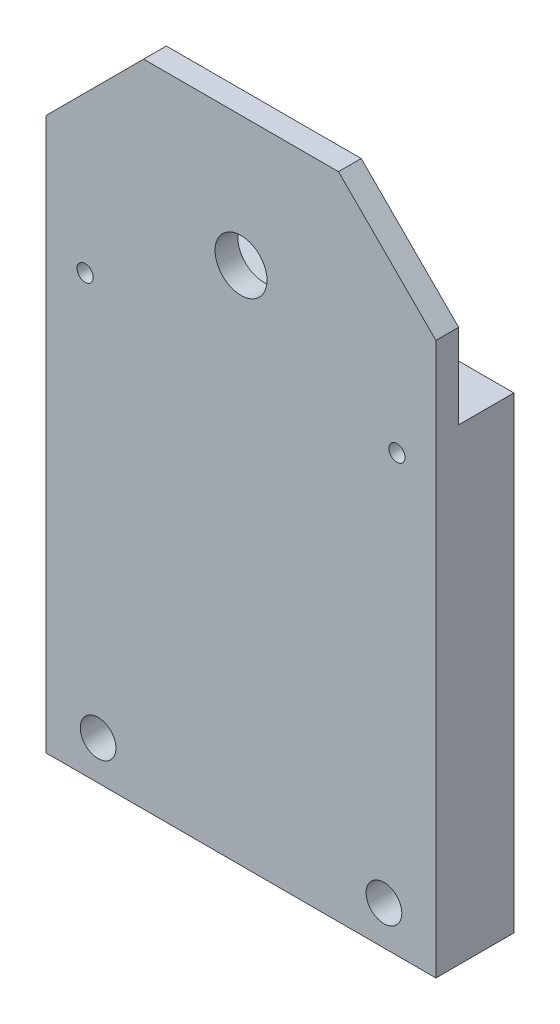
from build123d import *

# Parameters (mm, degrees)
ESQUISSE2_W                                        = 60
ESQUISSE2_H                                        = 100
BOSS_EXTRU_1_DEPTH                                 = 12
ESQUISSE3_R                                        = 4
ENL_V_MAT_EXTRU_1_DEPTH                            = 3.5
ESQUISSE5_W                                        = 8.5
ESQUISSE5_H                                        = 28
ENL_V_MAT_EXTRU_2_DEPTH                            = 61
TROU_TARAUD_M31_D                                  = 2.5
TROU_TARAUD_M32_D                                  = 2.5
CHAMBRAGE_POUR_VIS_T_TE_HEXAGONALE_M51_D           = 5.5
CHAMBRAGE_POUR_VIS_T_TE_HEXAGONALE_M51_CBORE_D     = 10
CHAMBRAGE_POUR_VIS_T_TE_HEXAGONALE_M51_CBORE_DEPTH = 5
CHAMBRAGE_POUR_VIS_T_TE_HEXAGONALE_M52_D           = 5.5
CHAMBRAGE_POUR_VIS_T_TE_HEXAGONALE_M52_CBORE_D     = 10
CHAMBRAGE_POUR_VIS_T_TE_HEXAGONALE_M52_CBORE_DEPTH = 5
CHANFREIN1_SIZE                                    = 15


with BuildPart() as part:
    # Esquisse2 → Boss.-Extru.1 (new body)
    with BuildSketch(Plane.XY):
        with Locations((30, 50)):
            Rectangle(ESQUISSE2_W, ESQUISSE2_H)
    extrude(amount=BOSS_EXTRU_1_DEPTH)

    # Esquisse3 → Enlèv. mat.-Extru.1 (cut)
    with BuildSketch(Plane.XY.offset(12)):
        with Locations((30, 80)):
            Circle(ESQUISSE3_R)
    extrude(amount=-ENL_V_MAT_EXTRU_1_DEPTH, mode=Mode.SUBTRACT)

    # Esquisse5 → Enlèv. mat.-Extru.2 (cut, through all)
    with BuildSketch(Plane.ZY):
        with Locations((4.25, 86)):
            Rectangle(ESQUISSE5_W, ESQUISSE5_H)
    extrude(amount=-ENL_V_MAT_EXTRU_2_DEPTH, mode=Mode.SUBTRACT)

    # Trou taraudé M31 (through all)
    with Locations(Plane.XY.offset(12)):
        with Locations((54, 67), (30, 80)):
            Hole(TROU_TARAUD_M31_D / 2)

    # Trou taraudé M32 (through all)
    with Locations(Plane.XY.offset(12)):
        with Locations((6, 67)):
            Hole(TROU_TARAUD_M32_D / 2)

    # Chambrage pour vis à tête hexagonale M51 (through all)
    with Locations(Plane(origin=(0, 0, 0), x_dir=(-1, 0, 0), z_dir=(0, 0, -1))):
        with Locations((-8, 6)):
            CounterBoreHole(CHAMBRAGE_POUR_VIS_T_TE_HEXAGONALE_M51_D / 2, CHAMBRAGE_POUR_VIS_T_TE_HEXAGONALE_M51_CBORE_D / 2, CHAMBRAGE_POUR_VIS_T_TE_HEXAGONALE_M51_CBORE_DEPTH)

    # Chambrage pour vis à tête hexagonale M52 (through all)
    with Locations(Plane(origin=(0, 0, 0), x_dir=(-1, 0, 0), z_dir=(0, 0, -1))):
        with Locations((-52, 6)):
            CounterBoreHole(CHAMBRAGE_POUR_VIS_T_TE_HEXAGONALE_M52_D / 2, CHAMBRAGE_POUR_VIS_T_TE_HEXAGONALE_M52_CBORE_D / 2, CHAMBRAGE_POUR_VIS_T_TE_HEXAGONALE_M52_CBORE_DEPTH)

    # Chanfrein1
    chanfrein1_edges = [part.edges().sort_by_distance(p)[0] for p in [
        (0, 100, 10.25),
        (60, 100, 10.25),
    ]]
    chamfer(chanfrein1_edges, length=CHANFREIN1_SIZE)


solid = part.part
